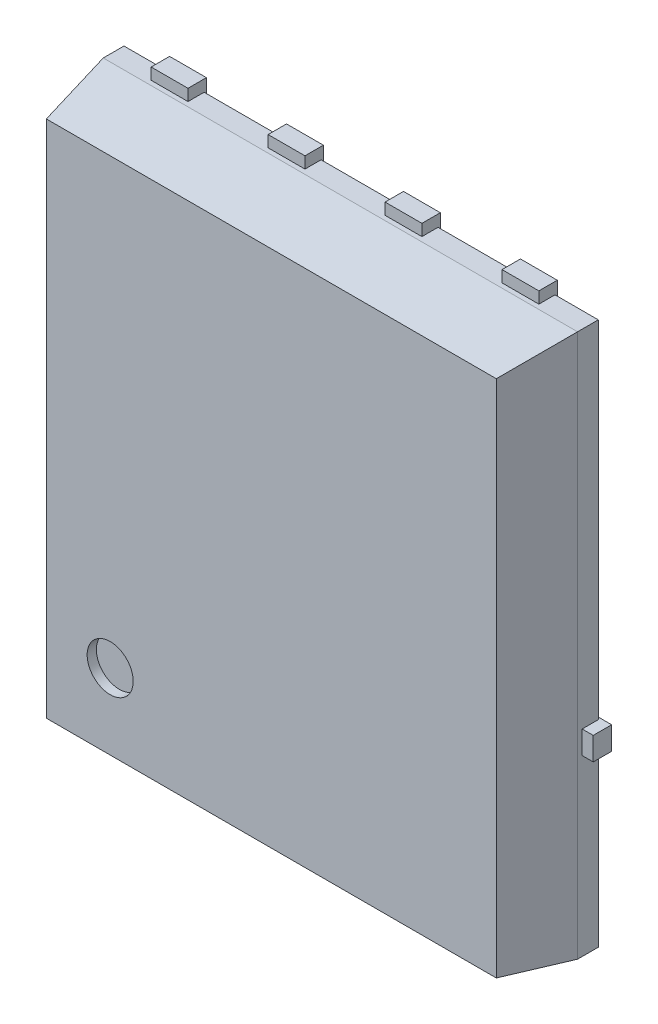
from build123d import *

# Parameters (mm, degrees)
PIN_EXTRUDE_DEPTH    = 0.2
ESBO_O1_W            = 0.4
ESBO_O1_H            = 0.55
PIN_EXTRUDE_2_DEPTH  = 0.2
PIN_EXTRUDE_3_DEPTH  = 0.2
PIN_EXTRUDE_4_DEPTH  = 0.2
PIN_EXTRUDE_5_DEPTH  = 0.2
BODY_START           = 0.25
ESBO_O3_W            = 5.15
ESBO_O3_H            = 5.9
BODY_DEPTH           = 0.75
BODY_TAPER           = 10
BODY_OTHER_WAY_DEPTH = 0.225
SKETCH_1_R           = 0.25
CUT_EXTRUDE_1_DEPTH  = 0.1


with BuildPart() as part:
    # Esboço1 → Pin Extrude (new body)
    with BuildSketch(Plane.XY):
        with BuildLine():
            Line((-0.435, 3.075), (-0.835, 3.075))
            Line((-0.835, 3.075), (-0.835, 2.775))
            ThreePointArc((-0.835, 2.775), (-0.908223305, 2.598223305), (-1.085, 2.525))
            Line((-1.085, 2.525), (-1.455, 2.525))
            ThreePointArc((-1.455, 2.525), (-1.631776695, 2.598223305), (-1.705, 2.775))
            Line((-1.705, 2.775), (-1.705, 3.075))
            Line((-1.705, 3.075), (-2.105, 3.075))
            Line((-2.105, 3.075), (-2.105, -0.56))
            ThreePointArc((-2.105, -0.56), (-2.178223305, -0.736776695), (-2.355, -0.81))
            Line((-2.355, -0.81), (-2.695, -0.81))
            Line((-2.695, -0.81), (-2.695, -1.06))
            Line((-2.695, -1.06), (2.695, -1.06))
            Line((2.695, -1.06), (2.695, -0.81))
            Line((2.695, -0.81), (2.355, -0.81))
            ThreePointArc((2.355, -0.81), (2.178223305, -0.736776695), (2.105, -0.56))
            Line((2.105, -0.56), (2.105, 3.075))
            Line((2.105, 3.075), (1.705, 3.075))
            Line((1.705, 3.075), (1.705, 2.775))
            ThreePointArc((1.705, 2.775), (1.631776695, 2.598223305), (1.455, 2.525))
            Line((1.455, 2.525), (1.085, 2.525))
            ThreePointArc((1.085, 2.525), (0.908223305, 2.598223305), (0.835, 2.775))
            Line((0.835, 2.775), (0.835, 3.075))
            Line((0.835, 3.075), (0.435, 3.075))
            Line((0.435, 3.075), (0.435, 2.775))
            ThreePointArc((0.435, 2.775), (0.361776695, 2.598223305), (0.185, 2.525))
            Line((0.185, 2.525), (-0.185, 2.525))
            ThreePointArc((-0.185, 2.525), (-0.361776695, 2.598223305), (-0.435, 2.775))
            Line((-0.435, 2.775), (-0.435, 3.075))
        make_face()
    extrude(amount=PIN_EXTRUDE_DEPTH)


with BuildPart() as body_2:
    # Esboço1 → Pin Extrude 2 (new body)
    with BuildSketch(Plane.XY):
        with Locations((0.635, -2.8)):
            Rectangle(ESBO_O1_W, ESBO_O1_H)
    extrude(amount=PIN_EXTRUDE_2_DEPTH)


with BuildPart() as body_3:
    # Esboço1 → Pin Extrude 3 (new body)
    with BuildSketch(Plane.XY):
        with Locations((1.905, -2.8)):
            Rectangle(ESBO_O1_W, ESBO_O1_H)
    extrude(amount=PIN_EXTRUDE_3_DEPTH)


with BuildPart() as body_4:
    # Esboço1 → Pin Extrude 4 (new body)
    with BuildSketch(Plane.XY):
        with Locations((-1.905, -2.8)):
            Rectangle(ESBO_O1_W, ESBO_O1_H)
    extrude(amount=PIN_EXTRUDE_4_DEPTH)


with BuildPart() as body_5:
    # Esboço1 → Pin Extrude 5 (new body)
    with BuildSketch(Plane.XY):
        with Locations((-0.635, -2.8)):
            Rectangle(ESBO_O1_W, ESBO_O1_H)
    extrude(amount=PIN_EXTRUDE_5_DEPTH)


with BuildPart() as body_6:
    # Esboço3 → Body (new body)
    with BuildSketch(Plane.XY.offset(BODY_START)):
        Rectangle(ESBO_O3_W, ESBO_O3_H)
    extrude(amount=BODY_DEPTH, taper=BODY_TAPER)

    # Esboço3 → Body other way (add)
    with BuildSketch(Plane.XY.offset(BODY_START)):
        Rectangle(ESBO_O3_W, ESBO_O3_H)
    extrude(amount=-BODY_OTHER_WAY_DEPTH)

    # Эскиз1 → Вырез-Вытянуть1 (cut)
    with BuildSketch(Plane.XY.offset(1)):
        with Locations((-1.75, -2)):
            Circle(SKETCH_1_R)
    extrude(amount=-CUT_EXTRUDE_1_DEPTH, mode=Mode.SUBTRACT)


solid = Compound([part.part, body_2.part, body_3.part, body_4.part, body_5.part, body_6.part])
